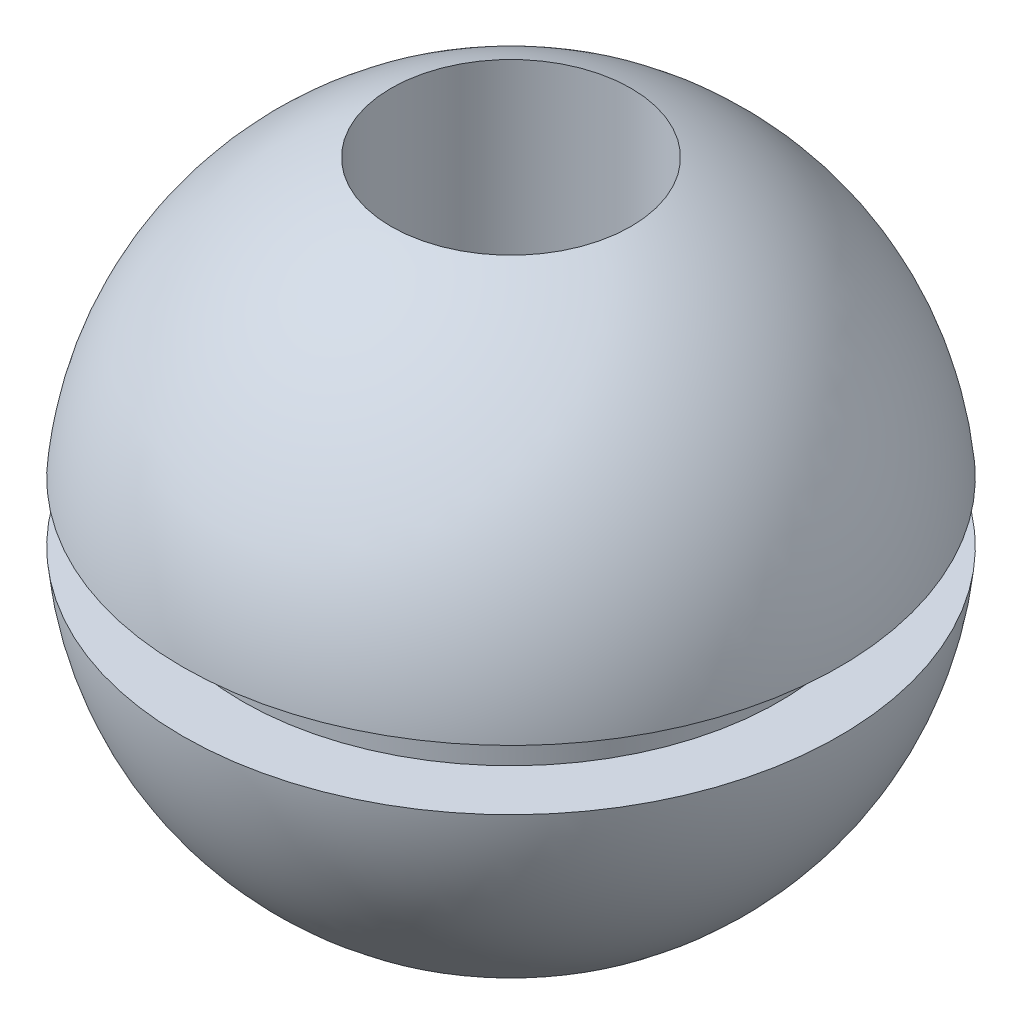
from build123d import *

# Parameters (mm, degrees)
SKICA2_R                 = 4
ODEBRAT_VYSUNUT_M1_DEPTH = 23


with BuildPart() as part:
    # Skica1 → Rotovat1 (revolve)
    with BuildSketch(Plane.XY, mode=Mode.PRIVATE) as rotovat1_sk:
        with BuildLine():
            Line((0, 0), (0, 22))
            ThreePointArc((0, 22), (7.416198487, 19.124038405), (10.95445115, 12))
            Line((10.95445115, 12), (8.95445115, 12))
            Line((8.95445115, 12), (8.95445115, 10))
            Line((8.95445115, 10), (10.95445115, 10))
            ThreePointArc((10.95445115, 10), (7.416198487, 2.875961595), (0, 0))
        make_face()
    revolve(rotovat1_sk.sketch.rotate(Axis((0, 0, 0), (0, 1, 0)), 90), axis=Axis((0, 0, 0), (0, 1, 0)))  # turned: the seam where the file's is

    # Skica2 → Odebrat vysunut_m1 (cut, through all)
    with BuildSketch(Plane(origin=(0, 0, 0), x_dir=(1, 0, 0), z_dir=(0, 1, 0))):
        with Locations(Location((0, 0, 0), (0, 0, 90))):  # turned: the seam where the file's is
            Circle(SKICA2_R)
    extrude(amount=ODEBRAT_VYSUNUT_M1_DEPTH, mode=Mode.SUBTRACT)


solid = part.part
